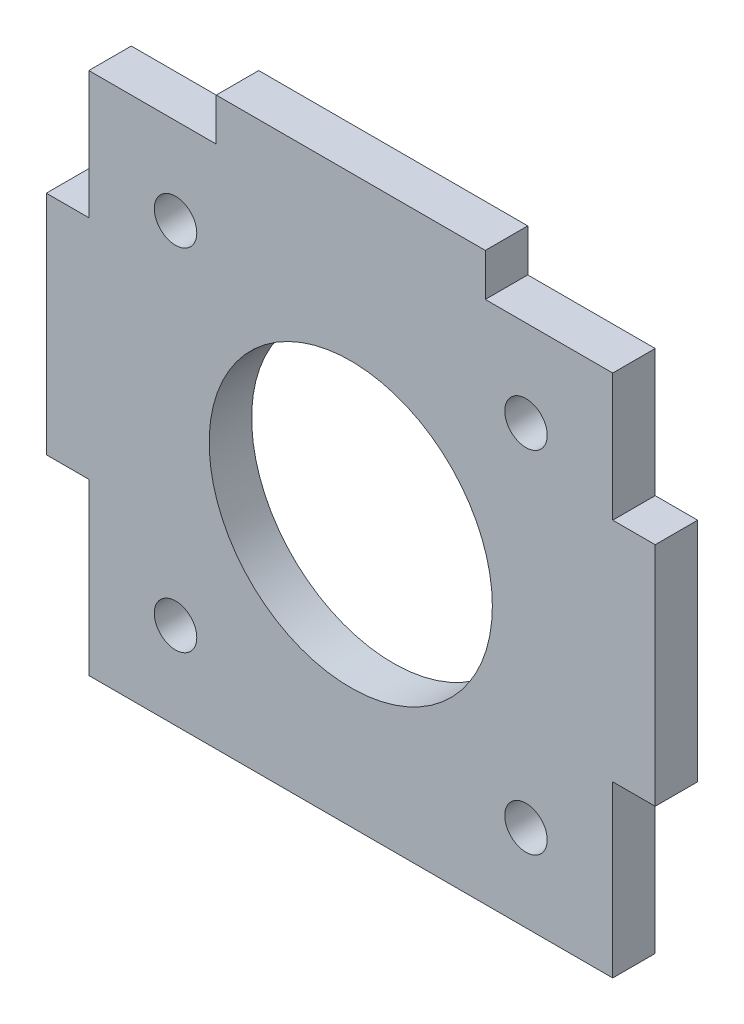
from build123d import *

# Parameters (mm, degrees)
SKETCH1_W           = 43
SKETCH1_H           = 43
SKETCH1_R           = 1.5
SKETCH1_R_2         = 10
BOSS_EXTRUDE1_DEPTH = 3
CUT_EXTRUDE1_DEPTH  = 3


with BuildPart() as part:
    # Sketch1 → Boss-Extrude1 (new body)
    with BuildSketch(Plane.XY):
        Rectangle(SKETCH1_W, SKETCH1_H)
        with Locations((-12.374368671, 12.374368671)):
            Circle(SKETCH1_R, mode=Mode.SUBTRACT)
        with Locations((12.374368671, -12.374368671)):
            Circle(SKETCH1_R, mode=Mode.SUBTRACT)
        with Locations((12.374368671, 12.374368671)):
            Circle(SKETCH1_R, mode=Mode.SUBTRACT)
        with Locations((-12.374368671, -12.374368671)):
            Circle(SKETCH1_R, mode=Mode.SUBTRACT)
        Circle(SKETCH1_R_2, mode=Mode.SUBTRACT)
    extrude(amount=BOSS_EXTRUDE1_DEPTH)

    # Sketch2 → Cut-Extrude1 (cut)
    with BuildSketch(Plane.XY.offset(3)):
        Polygon((-21.5, -21.5), (21.5, -21.5), (21.5, -18.5), (21.5, -6.5), (18.5, -6.5), (18.5, -18.5), (-18.5, -18.5), (-18.5, -6.5), (-21.5, -6.5), (-21.5, -18.5), align=None)
        Polygon((-21.5, 9.5), (-18.5, 9.5), (-18.5, 18.5), (-9.5, 18.5), (-9.5, 21.5), (-21.5, 21.5), align=None)
        Polygon((21.5, 9.5), (21.5, 21.5), (9.5, 21.5), (9.5, 18.5), (18.5, 18.5), (18.5, 9.5), align=None)
    extrude(amount=-CUT_EXTRUDE1_DEPTH, mode=Mode.SUBTRACT)


solid = part.part
